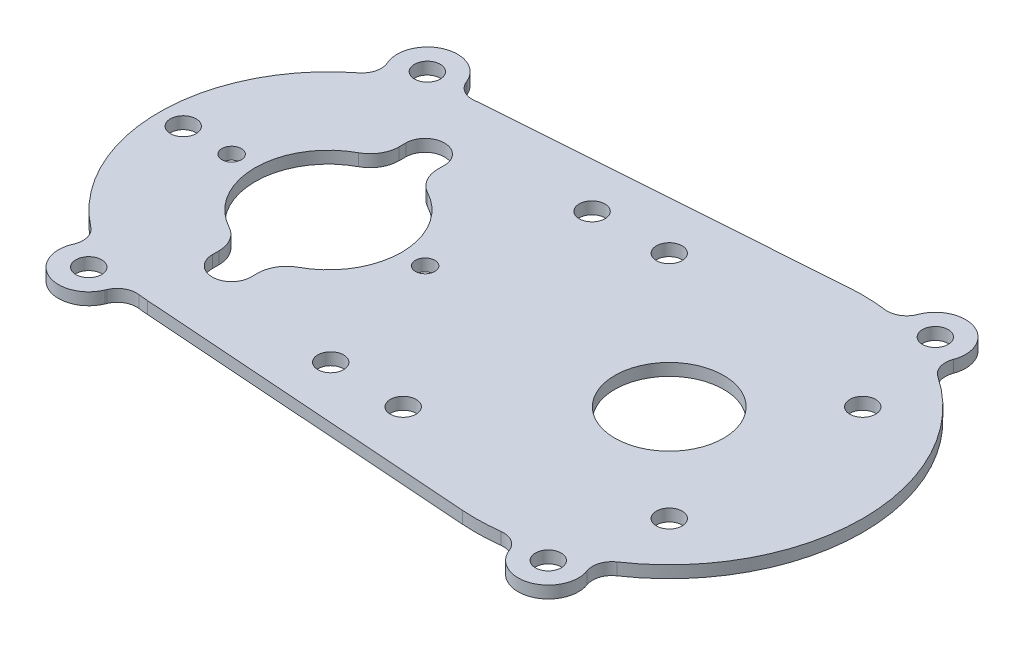
from build123d import *

# Parameters (mm, degrees)
SKETCH1_R               = 14.28115
SKETCH1_R_2             = 19.2405
BOSS_EXTRUDE1_DEPTH     = 3.175
F_10_CLEARANCE_HOLE1_D  = 5.1054
F_1_4_CLEARANCE_HOLE1_D = 6.7564
SKETCH6_R               = 2.5527
CUT_EXTRUDE1_DEPTH      = 4.175
FILLET1_R               = 7.62
BOSS_EXTRUDE3_DEPTH     = 3.175
FILLET2_R               = 5.08
F_1_4_CLEARANCE_HOLE2_D = 6.7564


with BuildPart() as part:
    # Sketch1 → Boss-Extrude1 (new body)
    with BuildSketch(Plane(origin=(0, 0, 0), x_dir=(1, 0, 0), z_dir=(0, 1, 0))):
        with BuildLine():
            Line((85.884602434, 50.671947857), (-3.15409287, 44.337954375))
            ThreePointArc((-3.15409287, 44.337954375), (-44.45, 0), (-3.15409287, -44.337954375))
            Line((-3.15409287, -44.337954375), (85.884602434, -50.671947857))
            ThreePointArc((85.884602434, -50.671947857), (140.28928, 0), (85.884602434, 50.671947857))
        make_face()
        with Locations((89.48928, 0)):
            Circle(SKETCH1_R, mode=Mode.SUBTRACT)
        Circle(SKETCH1_R_2, mode=Mode.SUBTRACT)
    extrude(amount=BOSS_EXTRUDE1_DEPTH)

    # #10 Clearance Hole1 (through all)
    with Locations(Plane(origin=(0, 3.175, 0), x_dir=(1, 0, 0), z_dir=(0, 1, 0))):
        with Locations((0, 25.4), (25.4, 0), (0, -25.4), (-25.4, 0)):
            Hole(F_10_CLEARANCE_HOLE1_D / 2)

    # 1/4 Clearance Hole1 (through all)
    with Locations(Plane(origin=(0, 3.175, 0), x_dir=(1, 0, 0), z_dir=(0, 1, 0))):
        with Locations((54.56428, 34.925), (54.56428, -34.925), (114.88928, 25.4), (114.88928, -25.4), (-38.1, 0), (34.925, -34.314713318), (34.925, 34.314713318)):
            Hole(F_1_4_CLEARANCE_HOLE1_D / 2)

    # Sketch6 → Cut-Extrude1 (cut, through all)
    with BuildSketch(Plane(origin=(0, 3.175, 0), x_dir=(1, 0, 0), z_dir=(0, 1, 0))):
        with BuildLine():
            Line((5.08, 18.55775957), (5.08, 25.4))
            ThreePointArc((5.08, 25.4), (0, 30.48), (-5.08, 25.4))
            Line((-5.08, 25.4), (-5.08, 18.55775957))
            ThreePointArc((-5.08, 18.55775957), (0, 19.2405), (5.08, 18.55775957))
        make_face()
        with Locations((0, 25.4)):
            Circle(SKETCH6_R, mode=Mode.SUBTRACT)
        with BuildLine():
            ThreePointArc((5.08, -18.55775957), (0, -19.2405), (-5.08, -18.55775957))
            Line((-5.08, -18.55775957), (-5.08, -25.4))
            ThreePointArc((-5.08, -25.4), (0, -30.48), (5.08, -25.4))
            Line((5.08, -25.4), (5.08, -18.55775957))
        make_face()
        with Locations((0, -25.4)):
            Circle(SKETCH6_R, mode=Mode.SUBTRACT)
    extrude(amount=-CUT_EXTRUDE1_DEPTH, mode=Mode.SUBTRACT)

    # Fillet1
    fillet1_edges = [part.edges().sort_by_distance(p)[0] for p in [
        (-5.08, 1.5875, 18.55775957),
        (5.08, 1.5875, 18.55775957),
        (5.08, 1.5875, -18.55775957),
        (-5.08, 1.5875, -18.55775957),
    ]]
    fillet(fillet1_edges, radius=FILLET1_R)

    # Sketch8 → Boss-Extrude3 (add)
    with BuildSketch(Plane(origin=(0, 3.175, 0), x_dir=(1, 0, 0), z_dir=(0, 1, 0))):
        with BuildLine():
            Line((114.539380559, -44.194258247), (115.971392847, -48.012957682))
            ThreePointArc((115.971392847, -48.012957682), (111.326322318, -58.232112847), (101.107167153, -53.587042318))
            Line((101.107167153, -53.587042318), (99.675154865, -49.768342882))
            ThreePointArc((99.675154865, -49.768342882), (107.326350833, -47.565522221), (114.539380559, -44.194258247))
        make_face()
        with BuildLine():
            Line((99.675154865, 49.768342882), (101.107167153, 53.587042318))
            ThreePointArc((101.107167153, 53.587042318), (111.326322318, 58.232112847), (115.971392847, 48.012957682))
            Line((115.971392847, 48.012957682), (114.539380559, 44.194258247))
            ThreePointArc((114.539380559, 44.194258247), (107.326350833, 47.565522221), (99.675154865, 49.768342882))
        make_face()
        with BuildLine():
            Line((-9.444374405, -43.435081353), (-11.130282191, -47.494435543))
            ThreePointArc((-11.130282191, -47.494435543), (-21.505155543, -51.780437809), (-25.791157809, -41.405564457))
            Line((-25.791157809, -41.405564457), (-24.105250023, -37.346210267))
            ThreePointArc((-24.105250023, -37.346210267), (-17.048839039, -41.050451732), (-9.444374405, -43.435081353))
        make_face()
        with BuildLine():
            Line((-9.444374405, 43.435081353), (-11.130282191, 47.494435543))
            ThreePointArc((-11.130282191, 47.494435543), (-21.505155543, 51.780437809), (-25.791157809, 41.405564457))
            Line((-25.791157809, 41.405564457), (-24.105250023, 37.346210267))
            ThreePointArc((-24.105250023, 37.346210267), (-17.048839039, 41.050451732), (-9.444374405, 43.435081353))
        make_face()
    extrude(amount=-BOSS_EXTRUDE3_DEPTH)

    # Fillet2
    fillet2_edges = [part.edges().sort_by_distance(p)[0] for p in [
        (99.675154865, 1.5875, -49.768342882),
        (114.539380559, 1.5875, -44.194258247),
        (-9.444374405, 1.5875, -43.435081353),
        (-24.105250023, 1.5875, -37.346210267),
        (-24.105250023, 1.5875, 37.346210267),
        (-9.444374405, 1.5875, 43.435081353),
        (114.539380559, 1.5875, 44.194258247),
        (99.675154865, 1.5875, 49.768342882),
    ]]
    fillet(fillet2_edges, radius=FILLET2_R)

    # 1/4 Clearance Hole2 (through all)
    with Locations(Plane(origin=(0, 3.175, 0), x_dir=(1, 0, 0), z_dir=(0, 1, 0))):
        with Locations((108.53928, -50.8), (-18.46072, -44.45), (-18.46072, 44.45), (108.53928, 50.8)):
            Hole(F_1_4_CLEARANCE_HOLE2_D / 2)


solid = part.part
